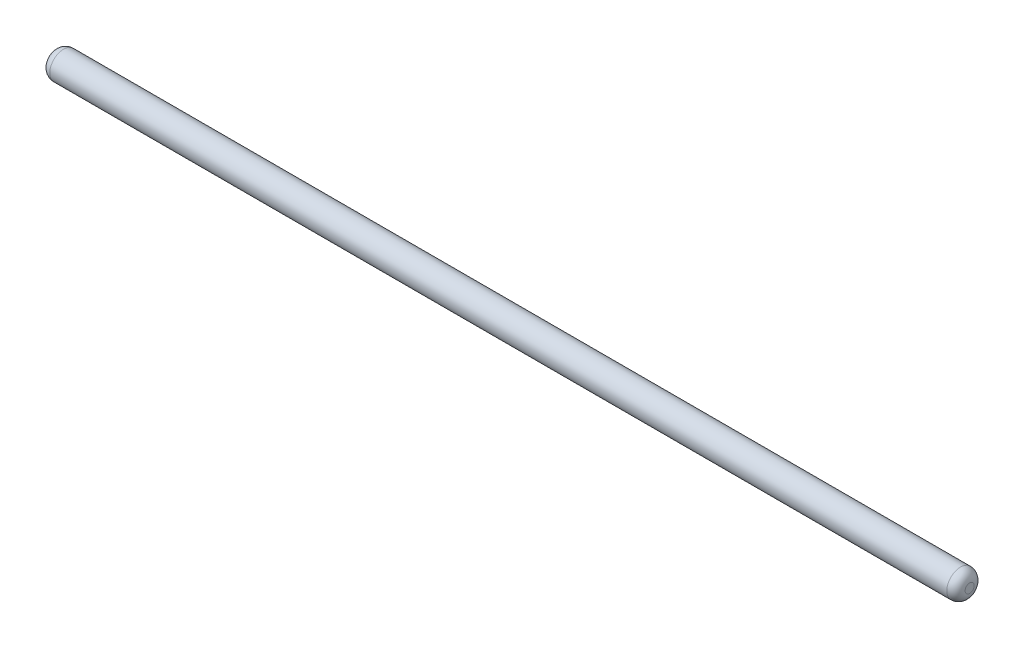
from build123d import *


with BuildPart() as part:
    # Schizzo2 → Rivoluzione1 (revolve)
    with BuildSketch(Plane.XY):
        with BuildLine():
            Line((0, 0), (100, 0))
            Line((100, 0), (100, 0.5))
            ThreePointArc((100, 0.5), (99.707106781, 1.207106781), (99, 1.5))
            Line((99, 1.5), (1, 1.5))
            ThreePointArc((1, 1.5), (0.292893219, 1.207106781), (0, 0.5))
            Line((0, 0.5), (0, 0))
        make_face()
    revolve(axis=Axis((0, 0, 0), (1, 0, 0)))


solid = part.part
